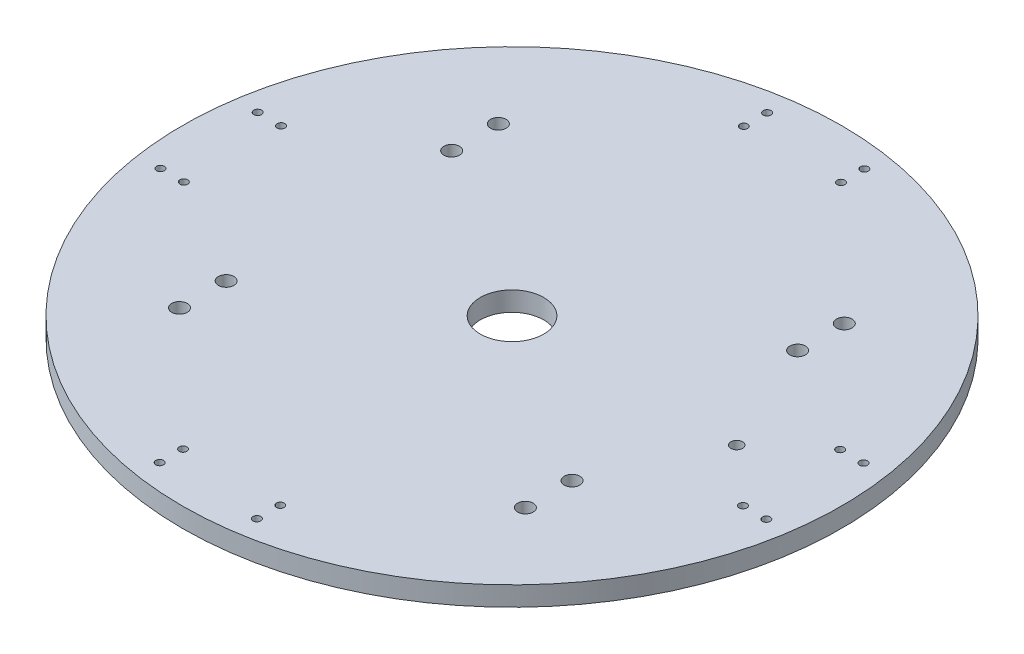
from build123d import *

# Parameters (mm, degrees)
SKETCH2_W                = 200
SKETCH2_H                = 200
BOSS_EXTRUDE2_DEPTH      = 60
BOSS_EXTRUDE3_START      = -38
BOSS_EXTRUDE3_DEPTH      = 41
SKETCH5_W                = 180
SKETCH5_H                = 180
CUT_EXTRUDE2_DEPTH       = 50
BOSS_EXTRUDE4_START      = -81.2
BOSS_EXTRUDE4_DEPTH      = 30
CUT_EXTRUDE3_DEPTH       = 35
CUT_EXTRUDE4_DEPTH       = 10
CUT_EXTRUDE6_START       = -26
CUT_EXTRUDE6_DEPTH       = 26
SKETCH11_W               = 120
SKETCH11_H               = 10
CUT_EXTRUDE7_DEPTH       = 26
SKETCH12_W               = 180
SKETCH12_H               = 50
CUT_EXTRUDE8_DEPTH       = 200
SKETCH13_W               = 180
SKETCH13_H               = 50
CUT_EXTRUDE9_DEPTH       = 200
SKETCH15_W               = 19.8
SKETCH15_H               = 40.6
CUT_EXTRUDE11_DEPTH      = 10
BOSS_EXTRUDE5_DEPTH      = 26
SKETCH20_W               = 19.8
SKETCH20_H               = 7
CUT_EXTRUDE14_DEPTH      = 8.2
SKETCH22_W               = 22
SKETCH22_H               = 68.38628635
SKETCH22_W_2             = 33
SKETCH22_H_2             = 70.357034464
CUT_EXTRUDE16_DEPTH      = 6
CUT_EXTRUDE17_DEPTH      = 150
SKETCH24_W               = 190
SKETCH24_H               = 55
CUT_EXTRUDE18_DEPTH      = 200
SKETCH41_W               = 200
SKETCH41_H               = 200
SKETCH41_W_2             = 115.381197846
SKETCH41_H_2             = 110.8
CUT_EXTRUDE25_DEPTH      = 100
CUT_EXTRUDE26_DEPTH      = 26
SKETCH43_R               = 85
BOSS_EXTRUDE9_DEPTH      = 5
CUT_EXTRUDE27_DEPTH      = 11
BOSS_EXTRUDE10_DEPTH     = 4
BOSS_EXTRUDE11_DEPTH     = 24
BOSS_EXTRUDE12_DEPTH     = 26
BOSS_EXTRUDE14_DEPTH     = 4
CUT_EXTRUDE29_DEPTH      = 18
CUT_EXTRUDE30_DEPTH      = 2
CUT_EXTRUDE31_DEPTH      = 2
SKETCH55_W               = 19.8
SKETCH55_H               = 2.410200662
BOSS_EXTRUDE16_DEPTH     = 4
SKETCH56_W               = 22
SKETCH56_H               = 70.356823689
CUT_EXTRUDE32_DEPTH      = 4
BOSS_EXTRUDE17_DEPTH     = 26
BOSS_EXTRUDE18_DEPTH     = 26
BOSS_EXTRUDE19_START     = 170
BOSS_EXTRUDE19_DEPTH     = 10
SKETCH60_R               = 2.45
BOSS_EXTRUDE20_DEPTH     = 9
FILLET1_R                = 0.3
CUT_EXTRUDE33_START      = -1
SKETCH61_R               = 2.45
SKETCH61_R_2             = 2.375
CUT_EXTRUDE33_DEPTH      = 5.2
FILLET2_R                = 2
BOSS_EXTRUDE21_START     = 140
BOSS_EXTRUDE21_DEPTH     = 10
SKETCH63_R               = 2.45
BOSS_EXTRUDE22_DEPTH     = 9
FILLET3_R                = 0.3
FILLET4_R                = 2
CUT_EXTRUDE34_START      = -1
SKETCH64_R               = 2.45
SKETCH64_R_2             = 2.375
CUT_EXTRUDE34_DEPTH      = 5.2
SKETCH67_R               = 95.168377016
SKETCH67_R_2             = 84.75
CUT_EXTRUDE36_DEPTH      = 5
SKETCH75_R               = 1.5
CUT_EXTRUDE38_DEPTH      = 300
CUT_EXTRUDE39_DEPTH      = 300
CUT_EXTRUDE39_DEPTH_BACK = 300
SKETCH73_W               = 180.242022847
SKETCH73_H               = 88.826117309
SKETCH73_W_2             = 185.11228995
SKETCH73_H_2             = 25.843302944
SKETCH76_R               = 8.16
CUT_EXTRUDE40_DEPTH      = 10
F_2_0MM_DOWEL_HOLE4_D    = 2
F_4_0MM_DOWEL_HOLE1_D    = 4


with BuildPart() as part:
    # Sketch2 → Boss-Extrude2 (new body)
    with BuildSketch(Plane(origin=(0, 0, 0), x_dir=(1, 0, 0), z_dir=(0, 1, 0))):
        with Locations((100, 100)):
            Rectangle(SKETCH2_W, SKETCH2_H)
    extrude(amount=BOSS_EXTRUDE2_DEPTH)

    # Sketch3 → Boss-Extrude3 (add)
    with BuildSketch(Plane.XY.offset(BOSS_EXTRUDE3_START)):
        with BuildLine():
            Line((40, 60), (80.980762114, 130.980762114))
            ThreePointArc((80.980762114, 130.980762114), (100, 141.961524227), (119.019237886, 130.980762114))
            Line((119.019237886, 130.980762114), (160, 60))
            Line((160, 60), (40, 60))
        make_face()
    extrude(amount=-BOSS_EXTRUDE3_DEPTH)

    # Sketch5 → Cut-Extrude2 (cut)
    with BuildSketch(Plane.XZ):
        with Locations((100, -100)):
            Rectangle(SKETCH5_W, SKETCH5_H)
    extrude(amount=-CUT_EXTRUDE2_DEPTH, mode=Mode.SUBTRACT)

    # Sketch7 → Boss-Extrude4 (add)
    with BuildSketch(Plane(origin=(0, 0, -200), x_dir=(-1, 0, 0), z_dir=(0, 0, -1)).offset(BOSS_EXTRUDE4_START)):
        with BuildLine():
            Line((-160, 60), (-40, 60))
            Line((-40, 60), (-80.980762114, 130.980762114))
            ThreePointArc((-80.980762114, 130.980762114), (-100, 141.961524227), (-119.019237886, 130.980762114))
            Line((-119.019237886, 130.980762114), (-160, 60))
        make_face()
    extrude(amount=BOSS_EXTRUDE4_DEPTH)

    # Sketch8 → Cut-Extrude3 (cut)
    with BuildSketch(Plane.XY.offset(-38)):
        with BuildLine():
            Line((48.660254038, 65), (151.339745962, 65))
            Line((151.339745962, 65), (114.689110868, 128.480762114))
            ThreePointArc((114.689110868, 128.480762114), (100, 136.961524227), (85.310889132, 128.480762114))
            Line((85.310889132, 128.480762114), (48.660254038, 65))
        make_face()
    extrude(amount=-CUT_EXTRUDE3_DEPTH, mode=Mode.SUBTRACT)

    # Sketch9 → Cut-Extrude4 (cut)
    with BuildSketch(Plane.XY.offset(-118.8)):
        with BuildLine():
            Line((95, 141.384773704), (95, 105))
            ThreePointArc((95, 105), (100, 100), (105, 105))
            Line((105, 105), (105, 141.384773704))
            ThreePointArc((105, 141.384773704), (100, 141.961524227), (95, 141.384773704))
        make_face()
    extrude(amount=-CUT_EXTRUDE4_DEPTH, mode=Mode.SUBTRACT)

    # Sketch10 → Cut-Extrude6 (cut)
    with BuildSketch(Plane(origin=(0, 0, -148.8), x_dir=(-1, 0, 0), z_dir=(0, 0, -1)).offset(CUT_EXTRUDE6_START)):
        with BuildLine():
            Line((-114.689110868, 128.480762114), (-151.339745962, 65))
            Line((-151.339745962, 65), (-48.660254038, 65))
            Line((-48.660254038, 65), (-85.310889132, 128.480762114))
            ThreePointArc((-85.310889132, 128.480762114), (-87.382612213, 131.335555987), (-90, 133.700120587))
            Line((-90, 133.700120587), (-90, 105))
            ThreePointArc((-90, 105), (-100, 95), (-110, 105))
            Line((-110, 105), (-110, 133.700120587))
            ThreePointArc((-110, 133.700120587), (-112.617387787, 131.335555987), (-114.689110868, 128.480762114))
        make_face()
    extrude(amount=CUT_EXTRUDE6_DEPTH, mode=Mode.SUBTRACT)

    # Sketch11 → Cut-Extrude7 (cut)
    with BuildSketch(Plane(origin=(0, 60, 0), x_dir=(1, 0, 0), z_dir=(0, 1, 0))):
        with Locations((100, 113.8)):
            Rectangle(SKETCH11_W, SKETCH11_H)
    extrude(amount=-CUT_EXTRUDE7_DEPTH, mode=Mode.SUBTRACT)

    # Sketch12 → Cut-Extrude8 (cut)
    with BuildSketch(Plane(origin=(200, 0, 0), x_dir=(0, 0, -1), z_dir=(1, 0, 0))):
        with Locations((100, 25)):
            Rectangle(SKETCH12_W, SKETCH12_H)
    extrude(amount=-CUT_EXTRUDE8_DEPTH, mode=Mode.SUBTRACT)

    # Sketch13 → Cut-Extrude9 (cut)
    with BuildSketch(Plane.XY):
        with Locations((100, 25)):
            Rectangle(SKETCH13_W, SKETCH13_H)
    extrude(amount=-CUT_EXTRUDE9_DEPTH, mode=Mode.SUBTRACT)

    # Sketch15 → Cut-Extrude11 (cut)
    with BuildSketch(Plane.XY.offset(-73)):
        with Locations((100, 94.7)):
            Rectangle(SKETCH15_W, SKETCH15_H)
    extrude(amount=-CUT_EXTRUDE11_DEPTH, mode=Mode.SUBTRACT)

    # Sketch16 → Boss-Extrude5 (add)
    with BuildSketch(Plane.XY.offset(-73)):
        Polygon((88.1, 115), (88.1, 72.4), (111.9, 72.4), (111.9, 115), (109.9, 115), (109.9, 74.4), (90.1, 74.4), (90.1, 115), align=None)
    extrude(amount=BOSS_EXTRUDE5_DEPTH)

    # Sketch20 → Cut-Extrude14 (cut)
    with BuildSketch(Plane(origin=(0, 0, -79), x_dir=(-1, 0, 0), z_dir=(0, 0, -1))):
        with Locations((-100, 118.5)):
            Rectangle(SKETCH20_W, SKETCH20_H)
        with Locations((-100, 70.9)):
            Rectangle(SKETCH20_W, SKETCH20_H)
    extrude(amount=-CUT_EXTRUDE14_DEPTH, mode=Mode.SUBTRACT)

    # Sketch22 → Cut-Extrude16 (cut)
    with BuildSketch(Plane(origin=(4.019237886, -2.320508076, 0), x_dir=(0, 0, 1), z_dir=(-0.8660254037844397, 0.49999999999999806, 0))):
        with Locations((-133.8, 115.729905279)):
            Rectangle(SKETCH22_W, SKETCH22_H)
        with Locations((-58.5, 116.744531222)):
            Rectangle(SKETCH22_W_2, SKETCH22_H_2)
    extrude(amount=-CUT_EXTRUDE16_DEPTH, mode=Mode.SUBTRACT)

    # Sketch23 → Cut-Extrude17 (cut)
    with BuildSketch(Plane.XY.offset(-38)):
        with BuildLine():
            Line((43.464101615, 62), (42.309401077, 60))
            Line((42.309401077, 60), (36.951802896, 60))
            Line((36.951802896, 60), (100, 183.688158135))
            Line((100, 183.688158135), (162.604774917, 60))
            Line((162.604774917, 60), (157.690598923, 60))
            Line((157.690598923, 60), (156.535898385, 62))
            Line((156.535898385, 62), (117.287187079, 129.980762114))
            ThreePointArc((117.287187079, 129.980762114), (100, 139.961524227), (82.712812921, 129.980762114))
            Line((82.712812921, 129.980762114), (43.464101615, 62))
        make_face()
    extrude(amount=-CUT_EXTRUDE17_DEPTH, mode=Mode.SUBTRACT)

    # Sketch24 → Cut-Extrude18 (cut)
    with BuildSketch(Plane(origin=(0, 0, -200), x_dir=(-1, 0, 0), z_dir=(0, 0, -1))):
        with Locations((-100, 27.5)):
            Rectangle(SKETCH24_W, SKETCH24_H)
    extrude(amount=-CUT_EXTRUDE18_DEPTH, mode=Mode.SUBTRACT)

    # Sketch41 → Cut-Extrude25 (cut)
    with BuildSketch(Plane(origin=(0, 60, 0), x_dir=(1, 0, 0), z_dir=(0, 1, 0))):
        with Locations((100, 100)):
            Rectangle(SKETCH41_W, SKETCH41_H)
        with Locations((100, 93.4)):
            Rectangle(SKETCH41_W_2, SKETCH41_H_2, mode=Mode.SUBTRACT)
    extrude(amount=-CUT_EXTRUDE25_DEPTH, mode=Mode.SUBTRACT)


with BuildPart() as cut_extrude25_piece_1:
    # of the separate pieces the step leaves, piece 1, a body of its own (cut_extrude25_pieces)
    add(part.part.solids().sort_by_distance((42.309401077, 55, -108.8))[0])



with BuildPart() as cut_extrude25_piece_2:
    # of the separate pieces the step leaves, piece 2, a body of its own (cut_extrude25_pieces)
    add(part.part.solids().sort_by_distance((42.309401077, 55, -118.8))[0])

    # Sketch38 → Cut-Extrude26 (cut)
    with BuildSketch(Plane(origin=(0, 0, -148.8), x_dir=(-1, 0, 0), z_dir=(0, 0, -1))):
        with BuildLine():
            Line((-110, 133.700120587), (-107, 135.763853262))
            Line((-107, 135.763853262), (-107, 105))
            ThreePointArc((-107, 105), (-100, 98), (-93, 105))
            Line((-93, 105), (-93, 135.763853262))
            Line((-93, 135.763853262), (-90, 133.700120587))
            Line((-90, 133.700120587), (-90, 105))
            ThreePointArc((-90, 105), (-100, 95), (-110, 105))
            Line((-110, 105), (-110, 133.700120587))
        make_face()
    extrude(amount=-CUT_EXTRUDE26_DEPTH, mode=Mode.SUBTRACT)


with BuildPart() as cut_extrude25_piece_1_1:
    add(cut_extrude25_piece_1.part)

    add(cut_extrude25_piece_2.part)  # Boss-Extrude9 merges Cut-Extrude25 piece 2
    # Sketch43 → Boss-Extrude9 (add)
    with BuildSketch(Plane.XZ.offset(-55)):
        with Locations((100, -98.8)):
            Circle(SKETCH43_R)
    extrude(amount=-BOSS_EXTRUDE9_DEPTH)

    # Sketch45 → Cut-Extrude27 (cut)
    with BuildSketch(Plane.XY.offset(-38)):
        with BuildLine():
            Line((42.309401077, 60), (82.712812921, 129.980762114))
            ThreePointArc((82.712812921, 129.980762114), (100, 139.961524227), (117.287187079, 129.980762114))
            Line((117.287187079, 129.980762114), (157.690598923, 60))
            Line((157.690598923, 60), (42.309401077, 60))
        make_face()
        with BuildLine():
            Line((151.339745962, 65), (114.689110868, 128.480762114))
            ThreePointArc((114.689110868, 128.480762114), (100, 136.961524227), (85.310889132, 128.480762114))
            Line((85.310889132, 128.480762114), (48.660254038, 65))
            Line((48.660254038, 65), (151.339745962, 65))
        make_face(mode=Mode.SUBTRACT)
    extrude(amount=-CUT_EXTRUDE27_DEPTH, mode=Mode.SUBTRACT)

    # Sketch46 → Boss-Extrude10 (add)
    with BuildSketch(Plane.XY.offset(-49)):
        Polygon((81.712812921, 128.248711306), (46.534295689, 67.317732125), (49.094273419, 65.839728294), (84.272790651, 126.770707475), align=None)
    extrude(amount=-BOSS_EXTRUDE10_DEPTH)

    # Sketch47 → Boss-Extrude11 (add)
    with BuildSketch(Plane.XY.offset(-73)):
        Polygon((49.1323719, 65.817732125), (50.548725488, 65), (48.660254038, 65), align=None)
    extrude(amount=BOSS_EXTRUDE11_DEPTH)

    # Sketch48 → Boss-Extrude12 (add)
    with BuildSketch(Plane(origin=(0, 0, -122.8), x_dir=(-1, 0, 0), z_dir=(0, 0, -1))):
        Polygon((-49.117745958, 65.792399249), (-50.490221717, 65), (-48.660254038, 65), align=None)
    extrude(amount=BOSS_EXTRUDE12_DEPTH)

    # Sketch49 → Boss-Extrude14 (add)
    with BuildSketch(Plane.XY.offset(-75)):
        Polygon((49.998397304, 65.317732125), (49.094273419, 65.839728294), (84.272790651, 126.770707475), (85.176914536, 126.248711306), align=None)
    extrude(amount=BOSS_EXTRUDE14_DEPTH)

    # Sketch52 → Cut-Extrude29 (cut)
    with BuildSketch(Plane(origin=(0, 0, -148.8), x_dir=(-1, 0, 0), z_dir=(0, 0, -1))):
        with BuildLine():
            Line((-93, 135.763853262), (-93, 105))
            ThreePointArc((-93, 105), (-100, 98), (-107, 105))
            Line((-107, 105), (-107, 135.763853262))
            ThreePointArc((-107, 135.763853262), (-100, 137.248161341), (-93, 135.763853262))
        make_face()
    extrude(amount=-CUT_EXTRUDE29_DEPTH, mode=Mode.SUBTRACT)

    # Sketch53 → Cut-Extrude30 (cut)
    with BuildSketch(Plane.XY.offset(-71)):
        Polygon((85.176914536, 126.248711306), (84.272790651, 126.770707475), (49.090707581, 65.833552081), (49.994831466, 65.311555913), align=None)
    extrude(amount=-CUT_EXTRUDE30_DEPTH, mode=Mode.SUBTRACT)

    # Sketch54 → Cut-Extrude31 (cut)
    with BuildSketch(Plane.XY.offset(-73)):
        with BuildLine():
            Line((50.548725488, 65), (151.339745962, 65))
            Line((151.339745962, 65), (114.689110868, 128.480762114))
            ThreePointArc((114.689110868, 128.480762114), (100, 136.961524227), (85.310889132, 128.480762114))
            Line((85.310889132, 128.480762114), (84.310889132, 126.748711306))
            Line((84.310889132, 126.748711306), (84.272790651, 126.770707475))
            Line((84.272790651, 126.770707475), (49.094273419, 65.839728294))
            Line((49.094273419, 65.839728294), (49.090707581, 65.833552081))
            Line((49.090707581, 65.833552081), (49.994831466, 65.311555913))
            Line((49.994831466, 65.311555913), (49.998397304, 65.317732125))
            Line((49.998397304, 65.317732125), (50.548725488, 65))
        make_face()
        Polygon((109.9, 67.4), (90.1, 67.4), (90.1, 72.4), (88.1, 72.4), (88.1, 115), (90.1, 115), (90.1, 122), (109.9, 122), (109.9, 115), (111.9, 115), (111.9, 72.4), (109.9, 72.4), align=None, mode=Mode.SUBTRACT)
    extrude(amount=-CUT_EXTRUDE31_DEPTH, mode=Mode.SUBTRACT)

    # Sketch55 → Boss-Extrude16 (add)
    with BuildSketch(Plane.XY.offset(-75)):
        with Locations((100, 66.194899669)):
            Rectangle(SKETCH55_W, SKETCH55_H)
    extrude(amount=BOSS_EXTRUDE16_DEPTH)

    # Sketch56 → Cut-Extrude32 (cut)
    with BuildSketch(Plane(origin=(144.248711306, 83.282032303, 0), x_dir=(0, 0, -1), z_dir=(0.8660254037844362, 0.5000000000000044, 0))):
        with Locations((64, 16.744636609)):
            Rectangle(SKETCH56_W, SKETCH56_H)
        with Locations((133.8, 16.744636609)):
            Rectangle(SKETCH56_W, SKETCH56_H)
    extrude(amount=-CUT_EXTRUDE32_DEPTH, mode=Mode.SUBTRACT)

    # Sketch57 → Boss-Extrude17 (add)
    with BuildSketch(Plane.XY.offset(-75)):
        Polygon((150.867522712, 65.817914662), (149.450852961, 65), (151.339745962, 65), align=None)
    extrude(amount=BOSS_EXTRUDE17_DEPTH)

    # Sketch58 → Boss-Extrude18 (add)
    with BuildSketch(Plane(origin=(0, 0, -122.8), x_dir=(-1, 0, 0), z_dir=(0, 0, -1))):
        Polygon((-150.867522712, 65.817914662), (-151.339745962, 65), (-149.450852961, 65), align=None)
    extrude(amount=BOSS_EXTRUDE18_DEPTH)

    # Sketch59 → Boss-Extrude19 (add)
    with BuildSketch(Plane(origin=(0, 0, 0), x_dir=(0, 0, -1), z_dir=(1, 0, 0)).offset(BOSS_EXTRUDE19_START)):
        with BuildLine():
            Line((81.4, 60), (94.15, 72.75))
            ThreePointArc((94.15, 72.75), (98.9, 74.717514421), (103.65, 72.75))
            Line((103.65, 72.75), (116.4, 60))
            Line((116.4, 60), (81.4, 60))
        make_face()
        with BuildLine():
            Line((81.4, 55), (116.4, 55))
            Line((116.4, 55), (103.65, 42.25))
            ThreePointArc((103.65, 42.25), (98.9, 40.282485579), (94.15, 42.25))
            Line((94.15, 42.25), (81.4, 55))
        make_face()
    extrude(amount=BOSS_EXTRUDE19_DEPTH)

    # Sketch60 → Boss-Extrude20 (add)
    with BuildSketch(Plane(origin=(180, 0, 0), x_dir=(0, 0, -1), z_dir=(1, 0, 0))):
        with Locations((98.9, 70)):
            Circle(SKETCH60_R)
        with Locations((98.9, 45)):
            Circle(SKETCH60_R)
    extrude(amount=BOSS_EXTRUDE20_DEPTH)

    # Fillet1
    fillet1_edges = [cut_extrude25_piece_1_1.edges().sort_by_distance(p)[0] for p in [
        (189, 70, -96.45),
        (189, 45, -96.45),
    ]]
    fillet(fillet1_edges, radius=FILLET1_R)

    # Sketch61 → Cut-Extrude33 (cut)
    # profile 1 of 2: a face of its own
    with BuildSketch(Plane(origin=(189, 0, 0), x_dir=(0, 0, -1), z_dir=(1, 0, 0)).offset(CUT_EXTRUDE33_START)):
        with Locations((98.9, 70)):
            Circle(SKETCH61_R)
        with Locations((98.9, 70)):
            Circle(SKETCH61_R_2, mode=Mode.SUBTRACT)
    # profile 2 of 2: a face of its own
    with BuildSketch(Plane(origin=(189, 0, 0), x_dir=(0, 0, -1), z_dir=(1, 0, 0)).offset(CUT_EXTRUDE33_START)):
        with Locations((98.9, 45)):
            Circle(SKETCH61_R)
        with Locations((98.9, 45)):
            Circle(SKETCH61_R_2, mode=Mode.SUBTRACT)
    extrude(amount=-CUT_EXTRUDE33_DEPTH, mode=Mode.SUBTRACT)

    # Fillet2
    fillet2_edges = [cut_extrude25_piece_1_1.edges().sort_by_distance(p)[0] for p in [
        (180, 70, -96.45),
        (180, 45, -96.45),
    ]]
    fillet(fillet2_edges, radius=FILLET2_R)

    # Sketch62 → Boss-Extrude21 (add)
    with BuildSketch(Plane.ZY.offset(-170).offset(BOSS_EXTRUDE21_START)):
        with BuildLine():
            Line((-81.4, 55), (-94.15, 42.25))
            ThreePointArc((-94.15, 42.25), (-98.9, 40.282485579), (-103.65, 42.25))
            Line((-103.65, 42.25), (-116.4, 55))
            Line((-116.4, 55), (-81.4, 55))
        make_face()
    extrude(amount=BOSS_EXTRUDE21_DEPTH)

    # Sketch63 → Boss-Extrude22 (add)
    with BuildSketch(Plane.ZY.offset(-20)):
        with Locations((-98.9, 45)):
            Circle(SKETCH63_R)
    extrude(amount=BOSS_EXTRUDE22_DEPTH)

    # Fillet3
    fillet3_edges = [cut_extrude25_piece_1_1.edges().sort_by_distance(p)[0] for p in [
        (11, 45, -101.35),
    ]]
    fillet(fillet3_edges, radius=FILLET3_R)

    # Fillet4
    fillet4_edges = [cut_extrude25_piece_1_1.edges().sort_by_distance(p)[0] for p in [
        (20, 45, -101.35),
    ]]
    fillet(fillet4_edges, radius=FILLET4_R)

    # Sketch64 → Cut-Extrude34 (cut)
    with BuildSketch(Plane.ZY.offset(-11).offset(CUT_EXTRUDE34_START)):
        with Locations((-98.9, 45)):
            Circle(SKETCH64_R)
        with Locations((-98.9, 45)):
            Circle(SKETCH64_R_2, mode=Mode.SUBTRACT)
    extrude(amount=-CUT_EXTRUDE34_DEPTH, mode=Mode.SUBTRACT)

    # Sketch67 → Cut-Extrude36 (cut)
    with BuildSketch(Plane(origin=(0, 60, 0), x_dir=(1, 0, 0), z_dir=(0, 1, 0))):
        with Locations((100, 98.8)):
            Circle(SKETCH67_R)
        with Locations((100, 98.8)):
            Circle(SKETCH67_R_2, mode=Mode.SUBTRACT)
    extrude(amount=-CUT_EXTRUDE36_DEPTH, mode=Mode.SUBTRACT)

    # Sketch75 → Cut-Extrude38 (cut)
    with BuildSketch(Plane(origin=(0, 60, 0), x_dir=(1, 0, 0), z_dir=(0, 1, 0))):
        with Locations((157.690598923, 98.9)):
            Circle(SKETCH75_R)
    extrude(amount=-CUT_EXTRUDE38_DEPTH, mode=Mode.SUBTRACT)

    # Sketch73 → Cut-Extrude39 (cut, two sides: drawn at the far end of the back side and taken through both)
    with BuildSketch(Plane(origin=(180, 0, 0), x_dir=(0, 0, -1), z_dir=(1, 0, 0)).offset(-CUT_EXTRUDE39_DEPTH_BACK)):
        with Locations((104.171011424, 104.413058655)):
            Rectangle(SKETCH73_W, SKETCH73_H)
        with Locations((106.606144975, 42.078348528)):
            Rectangle(SKETCH73_W_2, SKETCH73_H_2)
    extrude(amount=CUT_EXTRUDE39_DEPTH + CUT_EXTRUDE39_DEPTH_BACK, mode=Mode.SUBTRACT)

    # Sketch76 → Cut-Extrude40 (cut)
    with BuildSketch(Plane.XZ.offset(-55)):
        with Locations((100, -98.8)):
            Circle(SKETCH76_R)
    extrude(amount=-CUT_EXTRUDE40_DEPTH, mode=Mode.SUBTRACT)

    # Ø2.0mm Dowel Hole4 (through all)
    with Locations(Plane(origin=(28, 60, -111.4), x_dir=(0, 0, 1), z_dir=(0, 1, 0))):
        with Locations((0, 0), (0, -6), (25, 0), (25, -6), (84.6, 59.4), (90.6, 59.4), (90.6, 84.4), (84.6, 84.4), (25.2, 144), (25.2, 150), (0.2, 144), (0.2, 150), (-59.4, 59.6), (-59.4, 84.6), (-65.4, 59.6), (-65.4, 84.6)):
            Hole(F_2_0MM_DOWEL_HOLE4_D / 2)

    # Ø4.0mm Dowel Hole1 (through all)
    with Locations(Plane(origin=(55.490221717, 60, -69.8), x_dir=(0, 0, 1), z_dir=(0, 1, 0))):
        with Locations((0, 0), (12, 0), (12, 88.960631244), (0, 88.960631244), (-58, 0), (-70, 0), (-70, 88.960631244), (-58, 88.960631244)):
            Hole(F_4_0MM_DOWEL_HOLE1_D / 2)


solid = cut_extrude25_piece_1_1.part
